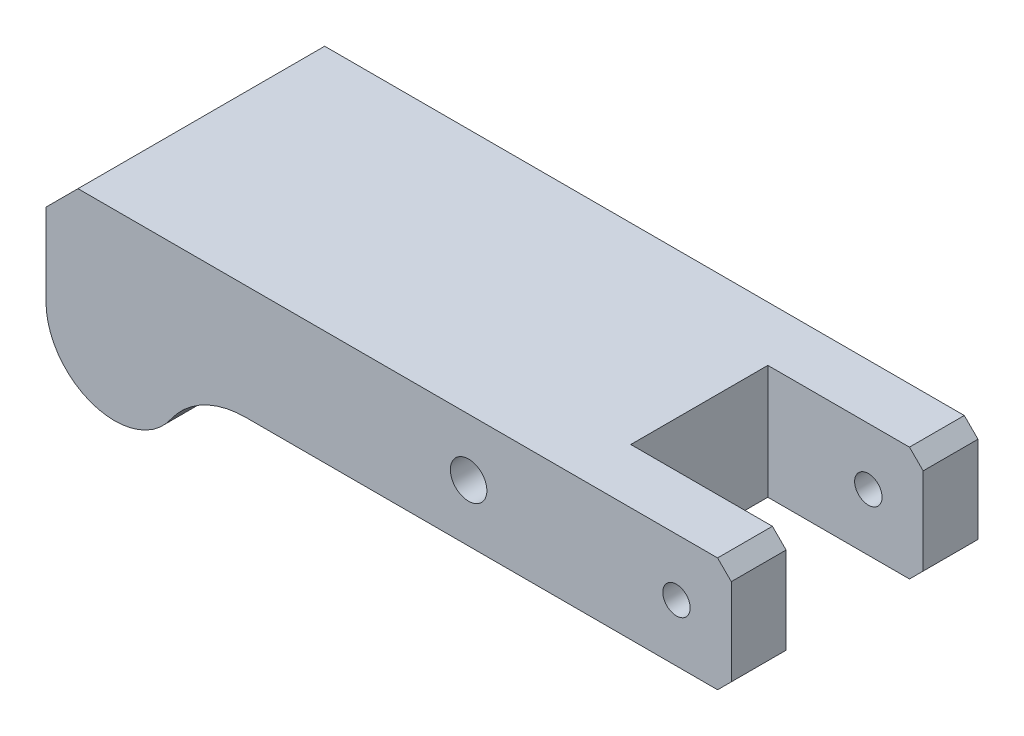
from build123d import *

# Parameters (mm, degrees)
SKETCH1_R           = 3
SKETCH1_R_2         = 4
BOSS_EXTRUDE1_DEPTH = 54
SKETCH2_W           = 34
SKETCH2_H           = 30
CUT_EXTRUDE1_DEPTH  = 54


with BuildPart() as part:
    # Sketch1 → Boss-Extrude1 (new body)
    with BuildSketch(Plane.XY):
        with BuildLine():
            Line((-59.598214286, 18), (-52.598214286, 25))
            Line((-52.598214286, 25), (87.401785714, 25))
            Line((87.401785714, 25), (90.401785714, 22))
            Line((90.401785714, 22), (90.401785714, 3))
            Line((90.401785714, 3), (87.401785714, 0))
            Line((87.401785714, 0), (-15.875401053, 0))
            ThreePointArc((-15.875401053, 0), (-25.133602051, -2.271894791), (-32.288437186, -8.571428571))
            ThreePointArc((-32.288437186, -8.571428571), (-49.090059313, -14.311650088), (-59.598214286, 0))
            Line((-59.598214286, 0), (-59.598214286, 18))
        make_face()
        with Locations((78.401785714, 12.5)):
            Circle(SKETCH1_R, mode=Mode.SUBTRACT)
        with Locations((32.901785714, 12.5)):
            Circle(SKETCH1_R_2, mode=Mode.SUBTRACT)
    extrude(amount=BOSS_EXTRUDE1_DEPTH)

    # Sketch2 → Cut-Extrude1 (cut)
    with BuildSketch(Plane(origin=(0, 25, 0), x_dir=(1, 0, 0), z_dir=(0, 1, 0))):
        with Locations((73.401785714, -27)):
            Rectangle(SKETCH2_W, SKETCH2_H)
    extrude(amount=-CUT_EXTRUDE1_DEPTH, mode=Mode.SUBTRACT)


solid = part.part
